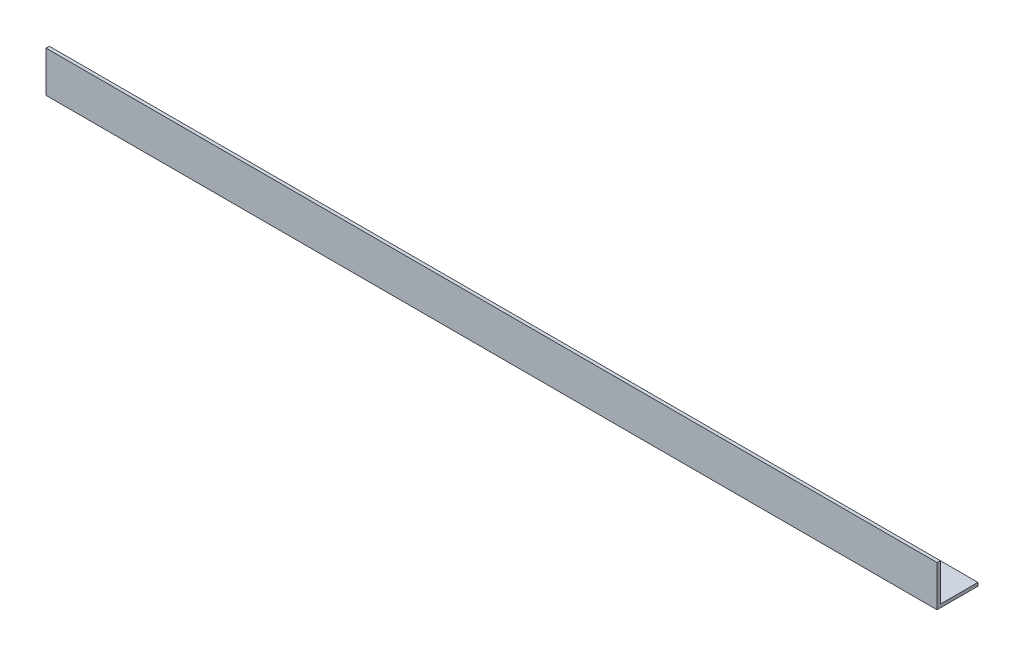
from build123d import *

# Parameters (mm, degrees)
EXTRUDE_1_DEPTH = 820


with BuildPart() as part:
    # Эскиз1 → Вытянуть-Тонкостенный1 (new body)
    with BuildSketch(Plane(origin=(0, 0, 0), x_dir=(0, 0, -1), z_dir=(1, 0, 0))):
        Polygon((0, 37.7), (0, 0), (37.7, 0), (37.7, 3), (3, 3), (3, 37.7), align=None)
    extrude(amount=EXTRUDE_1_DEPTH)


solid = part.part
